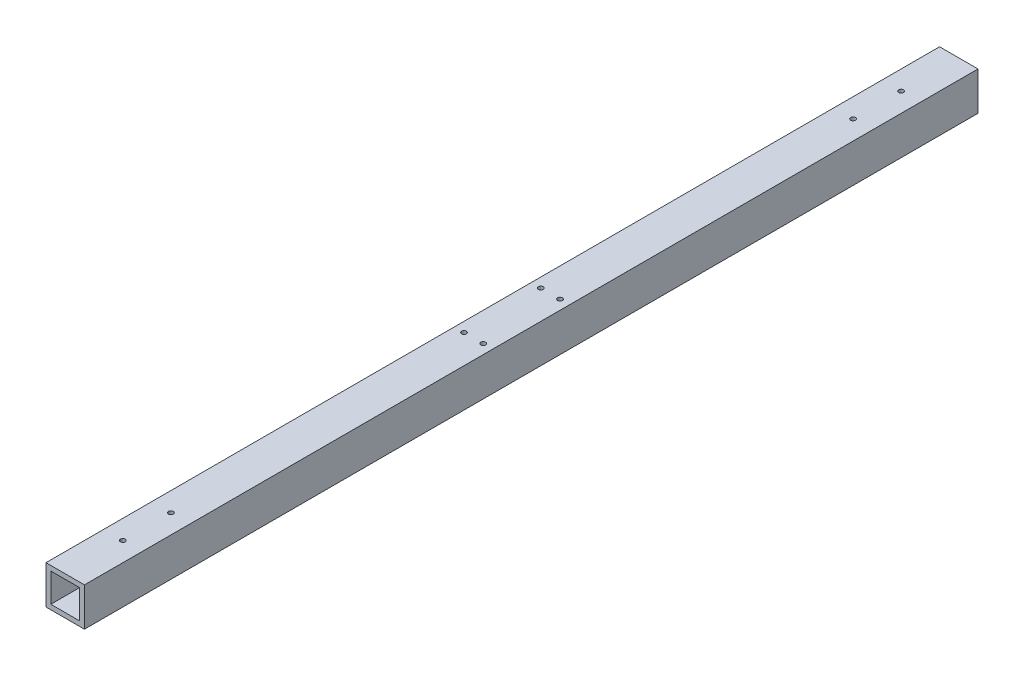
from build123d import *

# Parameters (mm, degrees)
SKETCH1_W                   = 50.8
SKETCH1_H                   = 50.8
BOSS_EXTRUDE1_DEPTH         = 1181.1
SKETCH8_W                   = 38.1
SKETCH8_H                   = 38.1
CUT_EXTRUDE1_DEPTH          = 1182.1
F_1_4_0_25_DIAMETER_HOLE1_D = 6.35
E_0_25_DIAMETER_HOLE2_D     = 6.35


with BuildPart() as part:
    # Sketch1 → Boss-Extrude1 (new body)
    with BuildSketch(Plane.XY):
        Rectangle(SKETCH1_W, SKETCH1_H)
    extrude(amount=BOSS_EXTRUDE1_DEPTH)

    # Sketch8 → Cut-Extrude1 (cut, through all)
    with BuildSketch(Plane.XY.offset(1181.1)):
        Rectangle(SKETCH8_W, SKETCH8_H)
    extrude(amount=-CUT_EXTRUDE1_DEPTH, mode=Mode.SUBTRACT)

    # 1/4 (0.25) Diameter Hole1 (through all)
    with Locations(Plane(origin=(0, 25.4, 0), x_dir=(1, 0, 0), z_dir=(0, 1, 0))):
        with Locations((-12.7, -641.35), (12.7, -641.35), (12.7, -539.75), (-12.7, -539.75)):
            Hole(F_1_4_0_25_DIAMETER_HOLE1_D / 2)

    # E (0.25) Diameter Hole2 (through all)
    with Locations(Plane(origin=(0, 25.4, 0), x_dir=(1, 0, 0), z_dir=(0, 1, 0))):
        with Locations((0, -1104.9), (0, -1041.4), (0, -139.7), (0, -76.2)):
            Hole(E_0_25_DIAMETER_HOLE2_D / 2)


solid = part.part
